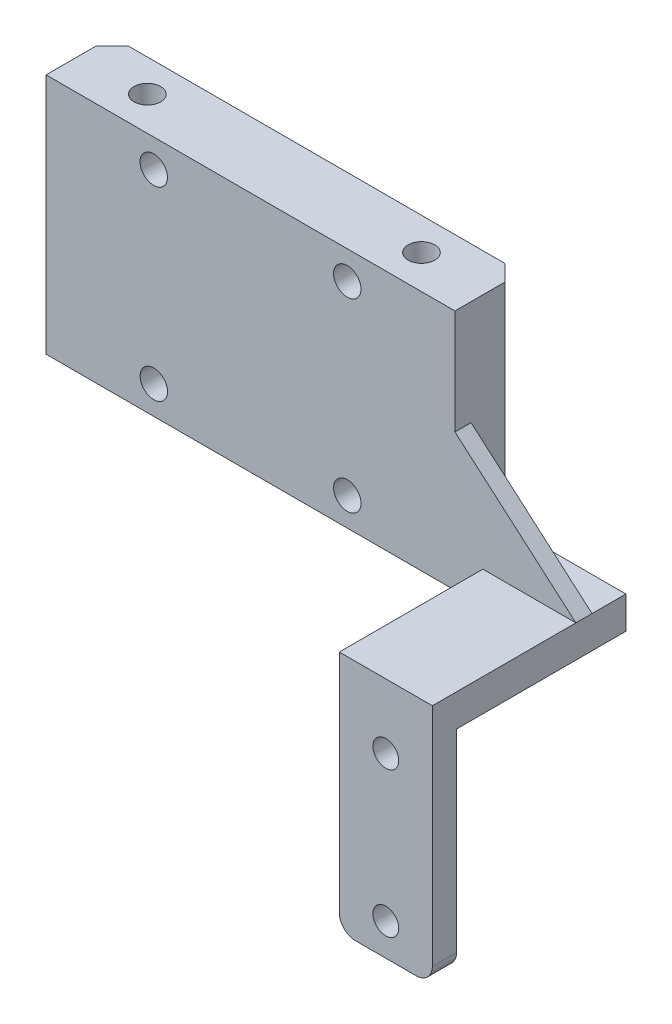
from build123d import *

# Parameters (mm, degrees)
SKETCH_1_W                   = 50.7
SKETCH_1_H                   = 30
EXTRUDE_1_DEPTH              = 8.2
CUT_EXTRUDE_1_DEPTH          = 31
HOLE_WIZARD_M3_1_D           = 3.4
HOLE_WIZARD_M3_1_CSINK_D     = 6.3
HOLE_WIZARD_M3_1_CSINK_ANGLE = 90
SKETCH_5_R                   = 1.65
CUT_EXTRUDE_2_DEPTH          = 31
SKETCH_6_W                   = 6.2
SKETCH_6_H                   = 5
EXTRUDE_2_DEPTH              = 15
SKETCH_9_W                   = 11.54
SKETCH_9_H                   = 5
EXTRUDE_7_DEPTH              = 17.8
SKETCH_10_W                  = 11.54
SKETCH_10_H                  = 3
EXTRUDE_8_DEPTH              = 26
SKETCH_11_R                  = 1.6
CUT_EXTRUDE_3_DEPTH          = 4
EXTRUDE_10_DEPTH             = 1
FILLET_1_R                   = 2
CUT_EXTRUDE_4_DEPTH          = 1
EXTRUDE_11_DEPTH             = 2


with BuildPart() as part:
    # 草图1 → 凸台-拉伸1 (new body)
    with BuildSketch(Plane.XY):
        with Locations((1.504794521, -4.292808219)):
            Rectangle(SKETCH_1_W, SKETCH_1_H)
    extrude(amount=EXTRUDE_1_DEPTH)

    # 草图2 → 切除-拉伸1 (cut, through all)
    with BuildSketch(Plane(origin=(0, 10.707191781, 0), x_dir=(1, 0, 0), z_dir=(0, 1, 0))):
        Polygon((-21.845205479, 0), (-23.845205479, -2), (-23.845205479, 0), align=None)
        Polygon((24.854794521, 0), (26.854794521, -2), (26.854794521, 0), align=None)
    extrude(amount=-CUT_EXTRUDE_1_DEPTH, mode=Mode.SUBTRACT)

    # M3 平头机械螺钉的锥形沉头孔1 (through all)
    with Locations(Plane(origin=(-10.486055507, -15.792808219, 0), x_dir=(-1, 0, 0), z_dir=(0, 0, -1))):
        with Locations((0, 0), (-23.990850028, 0), (-23.990850028, 23), (0.009149972, 23)):
            CounterSinkHole(HOLE_WIZARD_M3_1_D / 2, HOLE_WIZARD_M3_1_CSINK_D / 2, counter_sink_angle=HOLE_WIZARD_M3_1_CSINK_ANGLE)

    # 草图5 → 切除-拉伸2 (cut, through all)
    with BuildSketch(Plane.XZ.offset(19.292808219)):
        with Locations((-15.495205479, 4)):
            Circle(SKETCH_5_R)
        with Locations((18.504794521, 4)):
            Circle(SKETCH_5_R)
    extrude(amount=-CUT_EXTRUDE_2_DEPTH, mode=Mode.SUBTRACT)

    # 草图6 → 凸台-拉伸2 (add)
    with BuildSketch(Plane(origin=(26.854794521, 0, 0), x_dir=(0, 0, -1), z_dir=(1, 0, 0))):
        with Locations((-5.1, -16.792808219)):
            Rectangle(SKETCH_6_W, SKETCH_6_H)
    extrude(amount=EXTRUDE_2_DEPTH)

    # 草图9 → 凸台-拉伸7 (add)
    with BuildSketch(Plane.XY.offset(8.2)):
        with Locations((36.084794521, -16.792808219)):
            Rectangle(SKETCH_9_W, SKETCH_9_H)
    extrude(amount=EXTRUDE_7_DEPTH)

    # 草图10 → 凸台-拉伸8 (add)
    with BuildSketch(Plane.XZ.offset(19.292808219)):
        with Locations((36.084794521, 24.5)):
            Rectangle(SKETCH_10_W, SKETCH_10_H)
    extrude(amount=EXTRUDE_8_DEPTH)

    # 草图11 → 切除-拉伸3 (cut, through all)
    with BuildSketch(Plane(origin=(0, 0, 23), x_dir=(-1, 0, 0), z_dir=(0, 0, -1))):
        with Locations((-36.084794521, -41.292808219)):
            Circle(SKETCH_11_R)
        with Locations((-36.084794521, -23.292808219)):
            Circle(SKETCH_11_R)
    extrude(amount=-CUT_EXTRUDE_3_DEPTH, mode=Mode.SUBTRACT)

    # 草图15 → 凸台-拉伸10 (add)
    with BuildSketch(Plane.ZY.offset(-30.314794521)):
        Polygon((23, -24.883219003), (4.647869492, -19.292808219), (23, -19.292808219), align=None)
    extrude(amount=-EXTRUDE_10_DEPTH)

    # 圆角1
    fillet_1_edges = [part.edges().sort_by_distance(p)[0] for p in [
        (30.314794521, -45.292808219, 24.5),
        (41.854794521, -45.292808219, 24.5),
    ]]
    fillet(fillet_1_edges, radius=FILLET_1_R)

    # 草图17 → 切除-拉伸4 (cut)
    with BuildSketch(Plane(origin=(0, -14.292808219, 0), x_dir=(1, 0, 0), z_dir=(0, 1, 0))):
        Polygon((26.854794521, -8.2), (30.314794521, -8.2), (30.314794521, -26), (41.854794521, -26), (41.854794521, -2), (26.854794521, -2), align=None)
    extrude(amount=-CUT_EXTRUDE_4_DEPTH, mode=Mode.SUBTRACT)

    # 草图18 → 凸台-拉伸11 (add)
    with BuildSketch(Plane.XY.offset(8.2)):
        Polygon((26.854794521, -15.292808219), (30.314794521, -15.292808219), (41.854261071, -15.292808219), (26.854794521, -2.292808219), align=None)
    extrude(amount=-EXTRUDE_11_DEPTH)


solid = part.part
